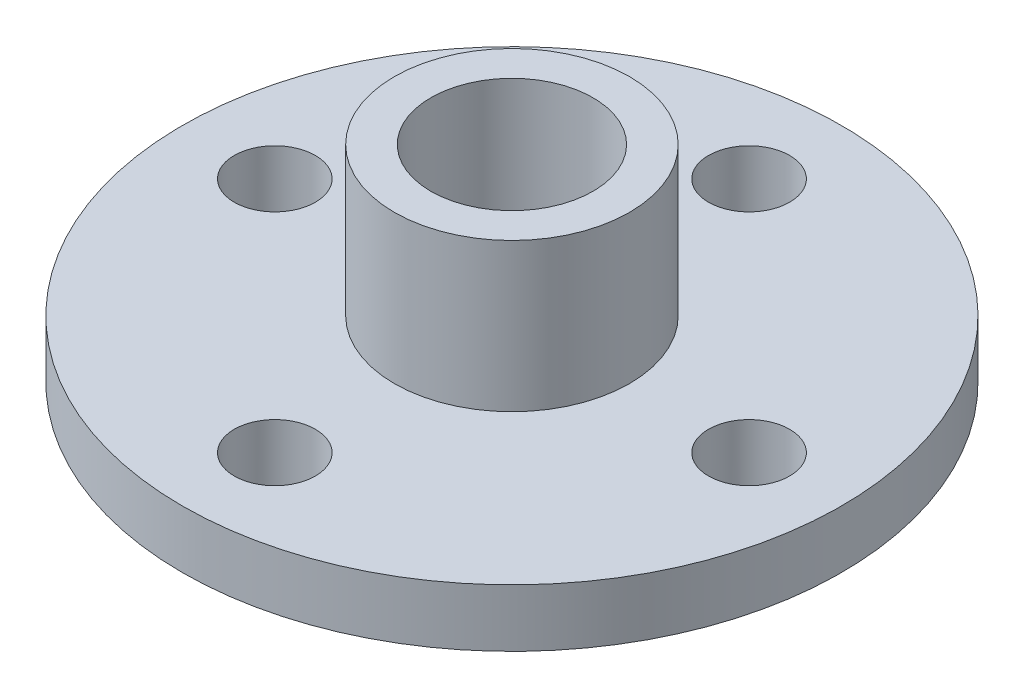
from build123d import *

# Parameters (mm, degrees)
SKETCH1_R           = 10.16
SKETCH1_R_2         = 1.625
BOSS_EXTRUDE2_DEPTH = 1.778
SKETCH3_R           = 3.625
SKETCH3_R_2         = 2.5
BOSS_EXTRUDE3_DEPTH = 4.572
SKETCH4_R           = 1.25
CUT_EXTRUDE1_DEPTH  = 7.35


with BuildPart() as part:
    # Sketch1 → Boss-Extrude2 (new body)
    with BuildSketch(Plane(origin=(0, 0, 0), x_dir=(1, 0, 0), z_dir=(0, 1, 0))):
        Circle(SKETCH1_R)
        Circle(SKETCH1_R_2, mode=Mode.SUBTRACT)
    extrude(amount=BOSS_EXTRUDE2_DEPTH)

    # Sketch3 → Boss-Extrude3 (add)
    with BuildSketch(Plane(origin=(0, 1.778, 0), x_dir=(1, 0, 0), z_dir=(0, 1, 0))):
        Circle(SKETCH3_R)
        Circle(SKETCH3_R_2, mode=Mode.SUBTRACT)
    extrude(amount=BOSS_EXTRUDE3_DEPTH)

    # Sketch4 → Cut-Extrude1 (cut, through all)
    with BuildSketch(Plane.XZ):
        with Locations((0, 7.31)):
            Circle(SKETCH4_R)
        with Locations((7.31, 0)):
            Circle(SKETCH4_R)
        with Locations((-7.31, 0)):
            Circle(SKETCH4_R)
        with Locations((0, -7.31)):
            Circle(SKETCH4_R)
    extrude(amount=-CUT_EXTRUDE1_DEPTH, mode=Mode.SUBTRACT)


solid = part.part
